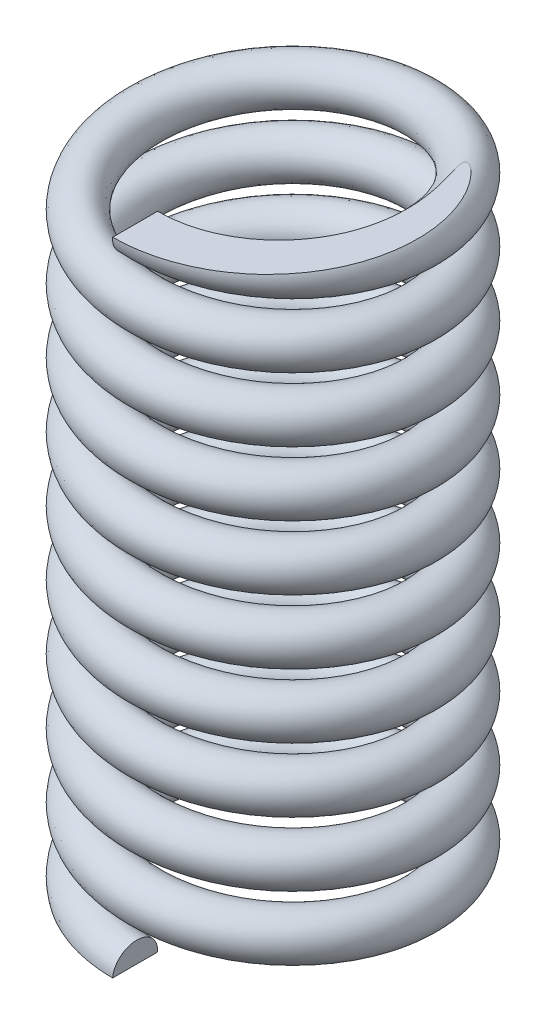
from build123d import *

# Parameters (mm, degrees)
SWEEP2_PITCH     = 1
SWEEP2_HEIGHT    = 10
SWEEP2_RADIUS    = 2.15
SWEEP2_PROFILE_R = 0.35


with BuildPart() as part:
    # Sweep2: sweep along a helix
    with BuildLine() as sweep2_path:
        Helix(SWEEP2_PITCH, SWEEP2_HEIGHT, SWEEP2_RADIUS, center=(0, 0, 0), direction=(0, 1, 0), lefthand=True)
    # Sweep2 profile (on start of the path) → Sweep2 (sweep)
    with BuildSketch(Plane(origin=(0, 0, 2.15), x_dir=(-0.073823563, -0.997271318, 0), z_dir=(-0.997271318, 0.073823563, 0))):
        Circle(SWEEP2_PROFILE_R)
    sweep(path=sweep2_path.line, is_frenet=True)

    # Sketch3 → Cut-Revolve1 (revolve, cut)
    with BuildSketch(Plane(origin=(0, 0, 0), x_dir=(0, 0, -1), z_dir=(1, 0, 0))):
        Polygon((0, 0), (-2.847527329, 0), (-2.847527329, 10), (0, 10), (0, 10.703100794), (-4.32187582, 10.703100794), (-4.32187582, -0.605638184), (0, -0.605638184), align=None)
    revolve(axis=Axis((0, -0.605638184, 0), (0, 1, 0)), mode=Mode.SUBTRACT)


solid = part.part
